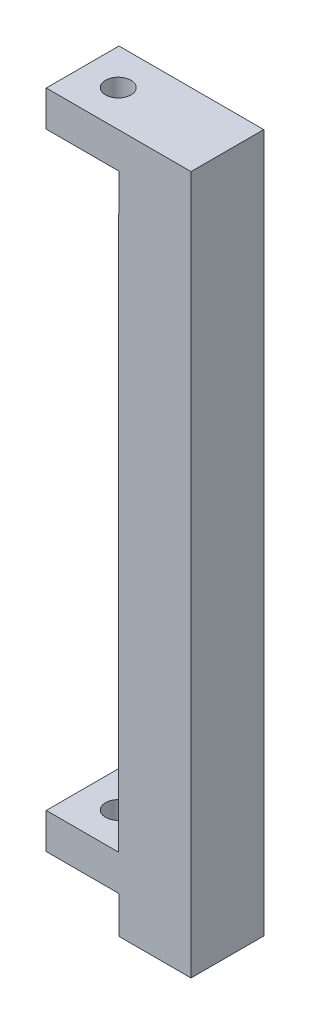
from build123d import *

# Parameters (mm, degrees)
BOSS_EXTRUDE1_DEPTH = 10
CUT_EXTRUDE1_DEPTH  = 11
SKETCH3_R           = 1.75
CUT_EXTRUDE2_DEPTH  = 91.9


with BuildPart() as part:
    # Sketch1 → Boss-Extrude1 (new body)
    with BuildSketch(Plane.XY):
        Polygon((0, 0), (0, 5), (-10, 5), (-10, 10), (0, 10), (0, 91), (-10, 91), (-10, 96), (10, 96), (10, 0), align=None)
    extrude(amount=-BOSS_EXTRUDE1_DEPTH)

    # Sketch2 → Cut-Extrude1 (cut, through all)
    with BuildSketch(Plane.XY):
        Polygon((-10, 10), (-10, 5), (0, 5), (0, 0), (0.1, 0), (0.1, 5.1), (-9.9, 5.1), (-9.9, 10), align=None)
        Polygon((-10, 96), (-10, 91), (0, 91), (0, 85.9), (0.1, 85.9), (0.1, 91.1), (-9.9, 91.1), (-9.9, 96), align=None)
    extrude(amount=-CUT_EXTRUDE1_DEPTH, mode=Mode.SUBTRACT)

    # Sketch3 → Cut-Extrude2 (cut, through all)
    with BuildSketch(Plane.XZ.offset(-5.1)):
        with Locations((-5, -5)):
            Circle(SKETCH3_R)
    extrude(amount=-CUT_EXTRUDE2_DEPTH, mode=Mode.SUBTRACT)


solid = part.part
